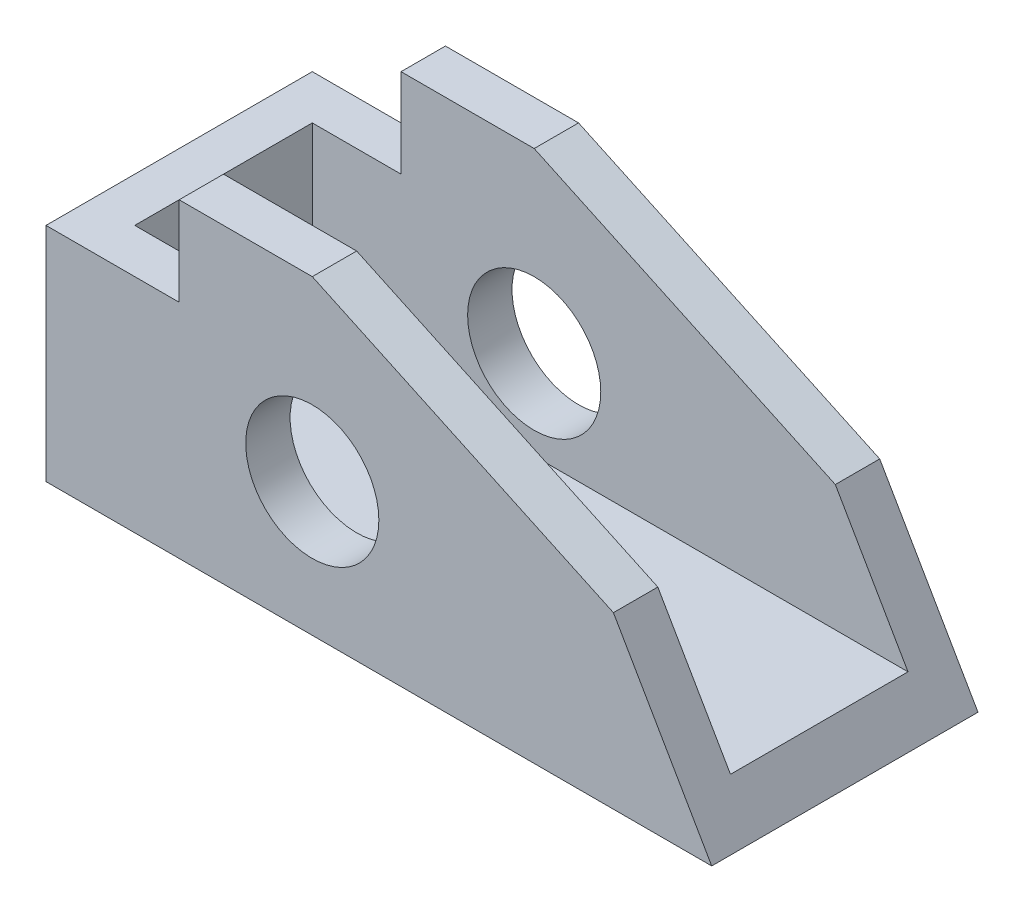
from build123d import *

# Parameters (mm, degrees)
BOSS_EXTRUDE1_DEPTH = 38.1
SKETCH2_R           = 9.525
CUT_EXTRUDE1_DEPTH  = 39.1
SKETCH3_W           = 88.9
SKETCH3_H           = 25.4
CUT_EXTRUDE2_DEPTH  = 38.1


with BuildPart() as part:
    # Sketch1 → Boss-Extrude1 (new body)
    with BuildSketch(Plane.XY):
        Polygon((0, 0), (95.25, 0), (81.186706555, 24.358338769), (38.1, 44.45), (19.05, 44.45), (19.05, 31.75), (0, 31.75), align=None)
    extrude(amount=-BOSS_EXTRUDE1_DEPTH)

    # Sketch2 → Cut-Extrude1 (cut, through all)
    with BuildSketch(Plane.XY):
        with Locations((38.1, 19.05)):
            Circle(SKETCH2_R)
    extrude(amount=-CUT_EXTRUDE1_DEPTH, mode=Mode.SUBTRACT)

    # Sketch3 → Cut-Extrude2 (cut)
    with BuildSketch(Plane(origin=(0, 44.45, 0), x_dir=(1, 0, 0), z_dir=(0, 1, 0))):
        with Locations((50.8, 19.05)):
            Rectangle(SKETCH3_W, SKETCH3_H)
    extrude(amount=-CUT_EXTRUDE2_DEPTH, mode=Mode.SUBTRACT)


solid = part.part
